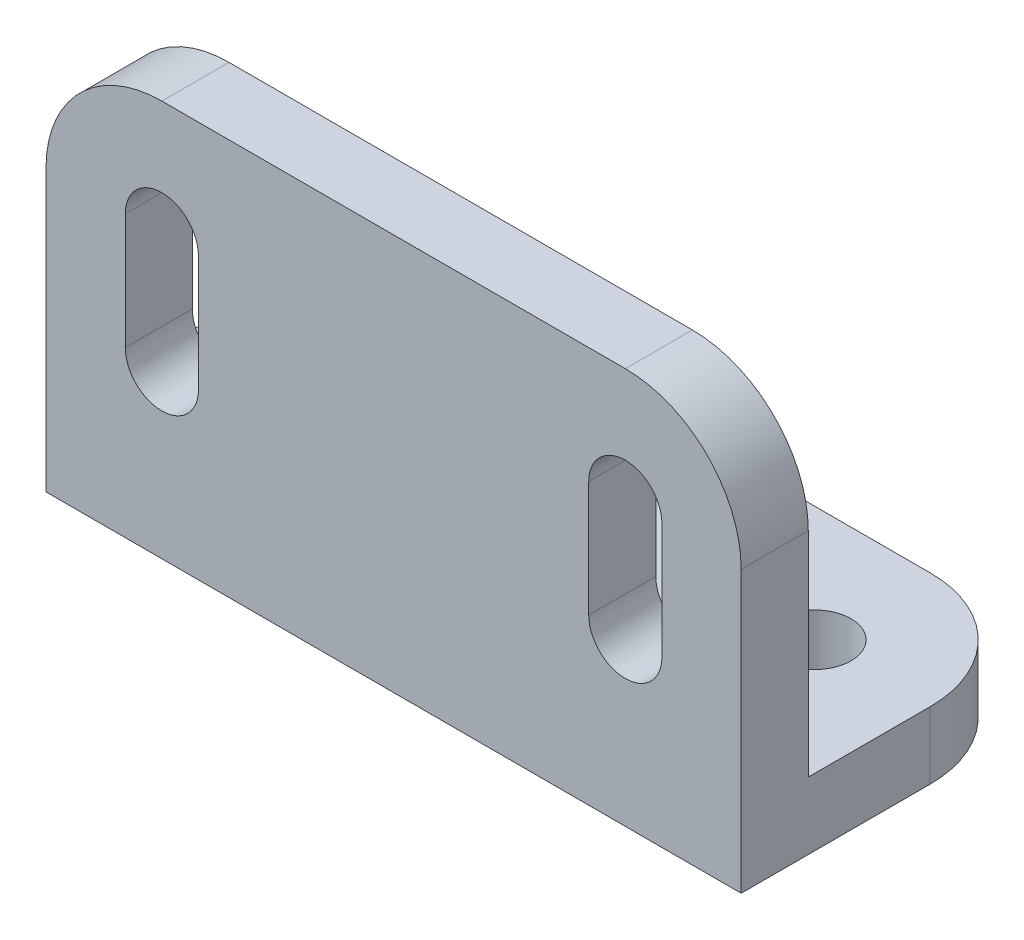
from build123d import *

# Parameters (mm, degrees)
SKETCH_2_W          = 114
SKETCH_2_H          = 50
EXTRUDE_1_DEPTH     = 11
FILLET_1_R          = 19
SKETCH_3_W          = 114
SKETCH_3_H          = 11
EXTRUDE_2_DEPTH     = 65
FILLET_2_R          = 19
SKETCH_4_R          = 6
CUT_EXTRUDE_1_DEPTH = 66
CUT_EXTRUDE_3_DEPTH = 65
EXTRUDE_3_DEPTH     = 3


with BuildPart() as part:
    # 스케치2 → 보스-돌출1 (new body)
    with BuildSketch(Plane(origin=(0, 0, 0), x_dir=(1, 0, 0), z_dir=(0, 1, 0))):
        with Locations((0, 25)):
            Rectangle(SKETCH_2_W, SKETCH_2_H)
    extrude(amount=EXTRUDE_1_DEPTH)

    # 필렛1
    fillet_1_edges = [part.edges().sort_by_distance(p)[0] for p in [
        (-57, 5.5, -50),
        (57, 5.5, -50),
    ]]
    fillet(fillet_1_edges, radius=FILLET_1_R)

    # 스케치3 → 보스-돌출2 (add)
    with BuildSketch(Plane(origin=(0, 0, 0), x_dir=(1, 0, 0), z_dir=(0, 1, 0))):
        with Locations((0, 5.5)):
            Rectangle(SKETCH_3_W, SKETCH_3_H)
    extrude(amount=EXTRUDE_2_DEPTH)

    # 필렛2
    fillet_2_edges = [part.edges().sort_by_distance(p)[0] for p in [
        (57, 65, -5.5),
        (-57, 65, -5.5),
    ]]
    fillet(fillet_2_edges, radius=FILLET_2_R)

    # 스케치4 → 컷-돌출1 (cut, through all)
    with BuildSketch(Plane(origin=(0, 0, 0), x_dir=(1, 0, 0), z_dir=(0, 1, 0))):
        with Locations((-38, 31)):
            Circle(SKETCH_4_R)
        with Locations((38, 31)):
            Circle(SKETCH_4_R)
    extrude(amount=CUT_EXTRUDE_1_DEPTH, mode=Mode.SUBTRACT)

    # 스케치5 → 컷-돌출3 (cut)
    with BuildSketch(Plane.XY):
        with BuildLine():
            Line((-44, 46), (-44, 27))
            ThreePointArc((-44, 27), (-38, 21), (-32, 27))
            Line((-32, 27), (-32, 46))
            ThreePointArc((-32, 46), (-38, 52), (-44, 46))
        make_face()
        with BuildLine():
            Line((32, 46), (32, 27))
            ThreePointArc((32, 27), (38, 21), (44, 27))
            Line((44, 27), (44, 46))
            ThreePointArc((44, 46), (38, 52), (32, 46))
        make_face()
    extrude(amount=-CUT_EXTRUDE_3_DEPTH, mode=Mode.SUBTRACT)

    # 스케치9 → 보스-돌출3 (add, symmetric)
    with BuildSketch(Plane(origin=(0, 0, 0), x_dir=(0, 0, -1), z_dir=(1, 0, 0))):
        Polygon((0, 65), (11, 65), (50, 11), (50, 0), (0, 0), align=None)
    extrude(amount=EXTRUDE_3_DEPTH, both=True)


solid = part.part
